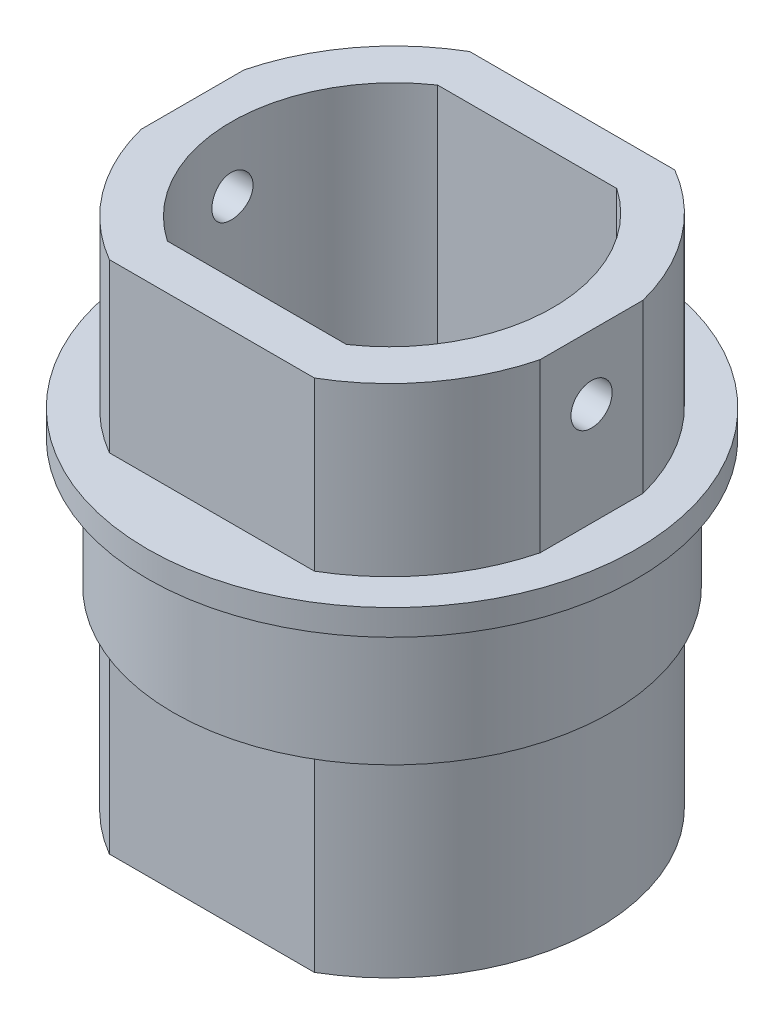
from build123d import *

# Parameters (mm, degrees)
BOSS_EXTRUDE3_DEPTH     = 20
BOSS_EXTRUDE5_DEPTH     = 1
SKETCH18_W              = 6.8
SKETCH18_H              = 5
CUT_EXTRUDE3_DEPTH      = 3
SKETCH25_R              = 8.5
BOSS_EXTRUDE6_DEPTH     = 2.5
SKETCH26_R              = 9.5
BOSS_EXTRUDE7_DEPTH     = 1
BOSS_EXTRUDE11_DEPTH    = 4
CUT_EXTRUDE7_DEPTH      = 4
SKETCH35_R              = 3.5
BOSS_EXTRUDE12_DEPTH    = 2
SKETCH36_R              = 0.8
CUT_EXTRUDE8_DEPTH      = 10.5
CUT_EXTRUDE8_DEPTH_BACK = 10.5
CUT_EXTRUDE9_DEPTH      = 6.5
CUT_EXTRUDE10_DEPTH     = 5
CUT_EXTRUDE11_DEPTH     = 19


with BuildPart() as part:
    # Sketch5 → Boss-Extrude3 (new body)
    with BuildSketch(Plane(origin=(0, 0, 0), x_dir=(1, 0, 0), z_dir=(0, 1, 0))):
        with BuildLine():
            Line((-3.983111349, -7), (3.983111349, -7))
            ThreePointArc((3.983111349, -7), (8, 0), (3.983111349, 7))
            Line((3.983111349, 7), (-3.983111349, 7))
            ThreePointArc((-3.983111349, 7), (-8, 0), (-3.983111349, -7))
        make_face()
        with BuildLine():
            Line((-3.4, -5), (3.4, -5))
            ThreePointArc((3.4, -5), (6, 0), (3.4, 5))
            Line((3.4, 5), (-3.4, 5))
            ThreePointArc((-3.4, 5), (-6, 0), (-3.4, -5))
        make_face(mode=Mode.SUBTRACT)
    extrude(amount=BOSS_EXTRUDE3_DEPTH)

    # Sketch7 → Boss-Extrude5 (add)
    with BuildSketch(Plane(origin=(0, 0, 0), x_dir=(1, 0, 0), z_dir=(0, 1, 0))):
        with BuildLine():
            Line((3.983111349, 7), (-3.983111349, 7))
            ThreePointArc((-3.983111349, 7), (-8, 0), (-3.983111349, -7))
            Line((-3.983111349, -7), (3.983111349, -7))
            ThreePointArc((3.983111349, -7), (8, 0), (3.983111349, 7))
        make_face()
    extrude(amount=BOSS_EXTRUDE5_DEPTH)

    # Sketch18 → Cut-Extrude3 (cut, through all)
    with BuildSketch(Plane.XY.offset(-5)):
        with Locations((0, 3.5)):
            Rectangle(SKETCH18_W, SKETCH18_H)
    extrude(amount=-CUT_EXTRUDE3_DEPTH, mode=Mode.SUBTRACT)

    # Sketch25 → Boss-Extrude6 (add, symmetric)
    with BuildSketch(Plane(origin=(0, 10, 0), x_dir=(1, 0, 0), z_dir=(0, 1, 0))):
        Circle(SKETCH25_R)
        with BuildLine():
            Line((3.983111349, 7), (-3.983111349, 7))
            ThreePointArc((-3.983111349, 7), (-8, 0), (-3.983111349, -7))
            Line((-3.983111349, -7), (3.983111349, -7))
            ThreePointArc((3.983111349, -7), (8, 0), (3.983111349, 7))
        make_face(mode=Mode.SUBTRACT)
    extrude(amount=BOSS_EXTRUDE6_DEPTH, both=True)

    # Sketch26 → Boss-Extrude7 (add)
    with BuildSketch(Plane(origin=(0, 12.5, 0), x_dir=(1, 0, 0), z_dir=(0, 1, 0))):
        Circle(SKETCH26_R)
        with BuildLine():
            Line((3.983111349, 7), (-3.983111349, 7))
            ThreePointArc((-3.983111349, 7), (-8, 0), (-3.983111349, -7))
            Line((-3.983111349, -7), (3.983111349, -7))
            ThreePointArc((3.983111349, -7), (8, 0), (3.983111349, 7))
        make_face(mode=Mode.SUBTRACT)
    extrude(amount=BOSS_EXTRUDE7_DEPTH)

    # Sketch32 → Boss-Extrude11 (add)
    with BuildSketch(Plane.XZ):
        with BuildLine():
            Line((-1.732050808, 1), (1.732050808, 1))
            ThreePointArc((1.732050808, 1), (0, -2), (-1.732050808, 1))
        make_face()
    extrude(amount=BOSS_EXTRUDE11_DEPTH)

    # Sketch34 → Cut-Extrude7 (cut)
    with BuildSketch(Plane.XZ.offset(4)):
        with BuildLine():
            Line((-1.118033989, 1), (1.118033989, 1))
            ThreePointArc((1.118033989, 1), (0, -1.5), (-1.118033989, 1))
        make_face()
    extrude(amount=-CUT_EXTRUDE7_DEPTH, mode=Mode.SUBTRACT)

    # Sketch35 → Boss-Extrude12 (add)
    with BuildSketch(Plane.XZ):
        Circle(SKETCH35_R)
        with BuildLine():
            Line((-1.118033989, 1), (1.118033989, 1))
            ThreePointArc((1.118033989, 1), (0, -1.5), (-1.118033989, 1))
        make_face(mode=Mode.SUBTRACT)
    extrude(amount=BOSS_EXTRUDE12_DEPTH)

    # Sketch36 → Cut-Extrude8 (cut, two sides)
    with BuildSketch(Plane(origin=(0, 0, 0), x_dir=(0, 0, -1), z_dir=(1, 0, 0))) as cut_extrude8_sk:
        with Locations((0, 17.5)):
            Circle(SKETCH36_R)
    extrude(amount=CUT_EXTRUDE8_DEPTH, mode=Mode.SUBTRACT)
    extrude(cut_extrude8_sk.sketch, amount=-CUT_EXTRUDE8_DEPTH_BACK, mode=Mode.SUBTRACT)

    # Sketch37 → Cut-Extrude9 (cut)
    with BuildSketch(Plane(origin=(0, 20, 0), x_dir=(1, 0, 0), z_dir=(0, 1, 0))):
        with BuildLine():
            Line((7.75, -1.997835367), (7.75, 1.997835367))
            ThreePointArc((7.75, 1.997835367), (8, 0), (7.75, -1.997835367))
        make_face()
        with BuildLine():
            Line((-7.75, -1.997835367), (-7.75, 1.997835367))
            ThreePointArc((-7.75, 1.997835367), (-8, 0), (-7.75, -1.997835367))
        make_face()
    extrude(amount=-CUT_EXTRUDE9_DEPTH, mode=Mode.SUBTRACT)

    # Sketch38 → Cut-Extrude10 (cut, through all)
    with BuildSketch(Plane.XZ):
        with BuildLine():
            Line((1.161895004, 1.1), (-1.161895004, 1.1))
            ThreePointArc((-1.161895004, 1.1), (0, -1.6), (1.161895004, 1.1))
        make_face()
    extrude(amount=CUT_EXTRUDE10_DEPTH, mode=Mode.SUBTRACT)

    # Sketch39 → Cut-Extrude11 (cut)
    with BuildSketch(Plane(origin=(0, 20, 0), x_dir=(1, 0, 0), z_dir=(0, 1, 0))):
        with BuildLine():
            Line((3.478078388, 5.25), (-3.478078388, 5.25))
            ThreePointArc((-3.478078388, 5.25), (-6.25, 0), (-3.478078388, -5.25))
            Line((-3.478078388, -5.25), (3.478078388, -5.25))
            ThreePointArc((3.478078388, -5.25), (6.25, 0), (3.478078388, 5.25))
        make_face()
        with BuildLine():
            Line((-3.4, 5), (3.4, 5))
            ThreePointArc((3.4, 5), (6, 0), (3.4, -5))
            Line((3.4, -5), (-3.4, -5))
            ThreePointArc((-3.4, -5), (-6, 0), (-3.4, 5))
        make_face(mode=Mode.SUBTRACT)
    extrude(amount=-CUT_EXTRUDE11_DEPTH, mode=Mode.SUBTRACT)


solid = part.part
